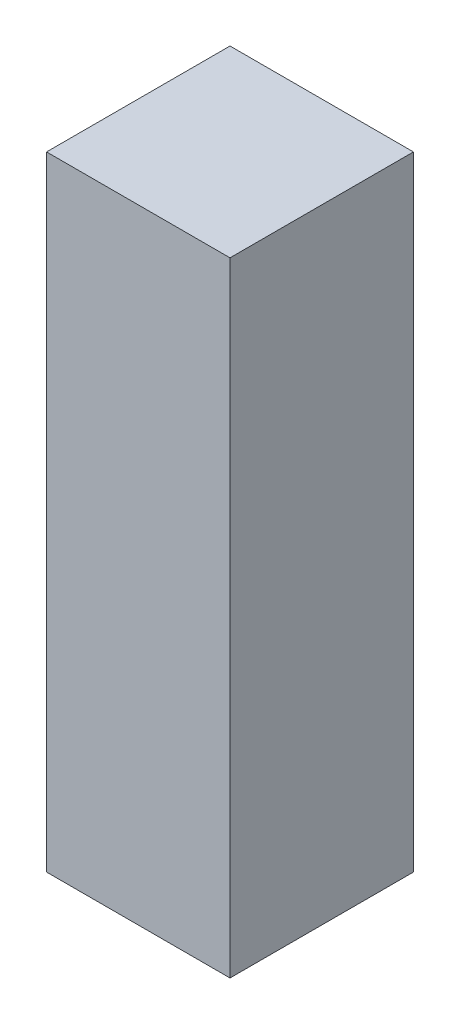
from build123d import *

# Parameters (mm, degrees)
SKETCH1_W           = 0.5
SKETCH1_H           = 0.5
BOSS_EXTRUDE1_DEPTH = 0.85


with BuildPart() as part:
    # Sketch1 → Boss-Extrude1 (new body, symmetric)
    with BuildSketch(Plane(origin=(0, 0, 0), x_dir=(1, 0, 0), z_dir=(0, 1, 0))):
        Rectangle(SKETCH1_W, SKETCH1_H)
    extrude(amount=BOSS_EXTRUDE1_DEPTH, both=True)


solid = part.part
